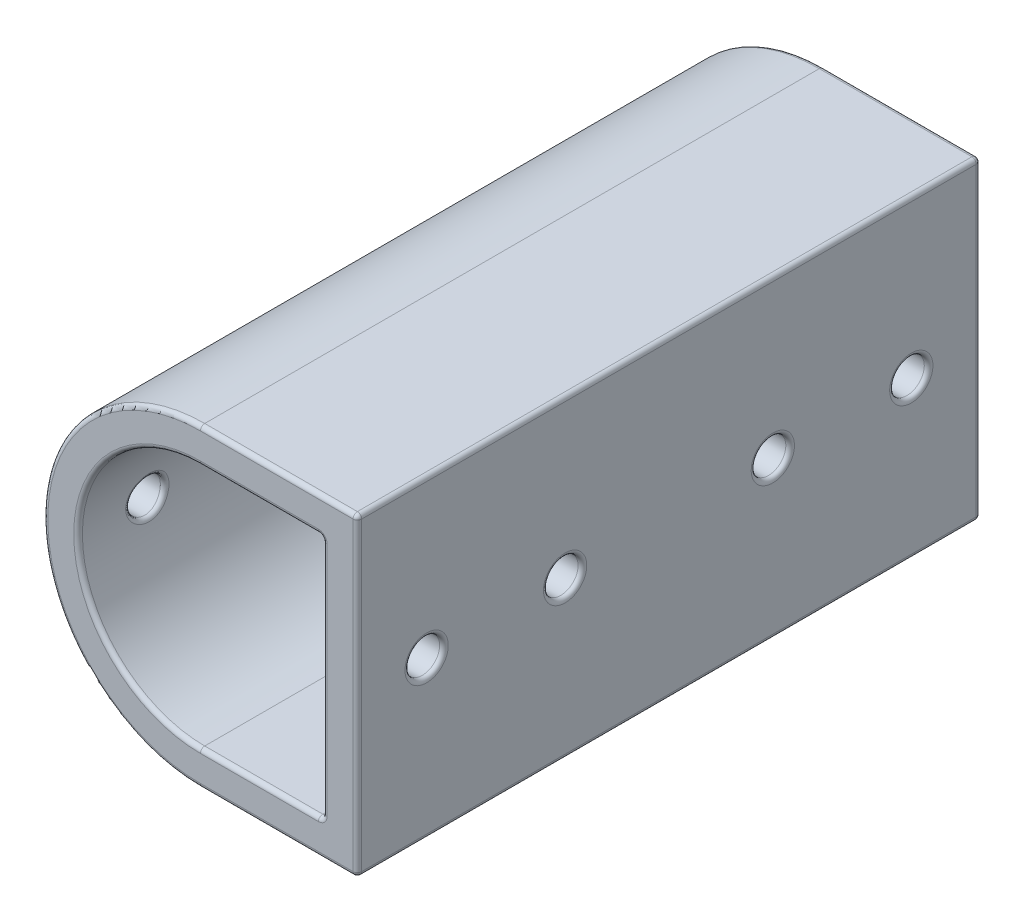
from build123d import *

# Parameters (mm, degrees)
BOSS_EXTRUDE2_DEPTH     = 57.15
CUT_EXTRUDE1_DEPTH      = 57.15
CUT_EXTRUDE1_DEPTH_BACK = 57.15
SKETCH3_R               = 1.5875
CUT_EXTRUDE2_DEPTH      = 38.1
FILLET2_R               = 0.396875


with BuildPart() as part:
    # Sketch2 → Boss-Extrude2 (new body)
    with BuildSketch(Plane.XY):
        with BuildLine():
            Line((0, 13.979196024), (14.39545, 13.979196024))
            Line((14.39545, 13.979196024), (14.39545, -14.811703976))
            Line((14.39545, -14.811703976), (0, -14.811703976))
            ThreePointArc((0, -14.811703976), (-14.39545, -0.416253976), (0, 13.979196024))
        make_face()
    extrude(amount=BOSS_EXTRUDE2_DEPTH)

    # Sketch2_10 → Cut-Extrude1 (cut, two sides: drawn at the far end of the back side and taken through both)
    with BuildSketch(Plane.XY.offset(-CUT_EXTRUDE1_DEPTH_BACK)):
        with BuildLine():
            Line((11.22045, -11.636703976), (0, -11.636703976))
            ThreePointArc((0, -11.636703976), (-11.22045, -0.416253976), (0, 10.804196024))
            Line((0, 10.804196024), (11.22045, 10.804196024))
            Line((11.22045, 10.804196024), (11.22045, -11.636703976))
        make_face()
    extrude(amount=CUT_EXTRUDE1_DEPTH + CUT_EXTRUDE1_DEPTH_BACK, mode=Mode.SUBTRACT)

    # Sketch3 → Cut-Extrude2 (cut)
    with BuildSketch(Plane(origin=(14.39545, 0, 0), x_dir=(0, 0, -1), z_dir=(1, 0, 0))):
        with Locations((-50.8, -0.416253976)):
            Circle(SKETCH3_R)
        with Locations((-38.1, -0.416253976)):
            Circle(SKETCH3_R)
        with Locations((-19.05, -0.416253976)):
            Circle(SKETCH3_R)
        with Locations((-6.35, -0.416253976)):
            Circle(SKETCH3_R)
    extrude(amount=-CUT_EXTRUDE2_DEPTH, mode=Mode.SUBTRACT)

    # Fillet2
    fillet2_edges = [part.edges().sort_by_distance(p)[0] for p in [
        (7.197725, 13.979196024, 57.15),
        (7.197725, -14.811703976, 57.15),
        (7.197725, 13.979196024, 0),
        (7.197725, -14.811703976, 0),
        (5.610225, -11.636703976, 0),
        (5.610225, -11.636703976, 57.15),
        (11.22045, -0.416253976, 57.15),
        (11.22045, -11.636703976, 28.575),
        (11.22045, -0.416253976, 0),
        (11.22045, -0.416253976, 7.9375),
        (11.22045, -0.416253976, 20.6375),
        (11.22045, -0.416253976, 39.6875),
        (11.22045, -0.416253976, 52.3875),
        (14.39545, -14.811703976, 28.575),
        (14.39545, -0.416253976, 57.15),
        (14.39545, 13.979196024, 28.575),
        (14.39545, -0.416253976, 0),
        (14.39545, -0.416253976, 7.9375),
        (14.39545, -0.416253976, 20.6375),
        (14.39545, -0.416253976, 39.6875),
        (14.39545, -0.416253976, 52.3875),
        (5.610225, 10.804196024, 57.15),
        (11.22045, 10.804196024, 28.575),
        (5.610225, 10.804196024, 0),
        (-11.22045, -0.416253976, 0),
        (-11.22045, -0.416253976, 57.15),
        (-11.22045, -0.416253972, 7.937500006),
        (-11.22045, -0.416253972, 20.637500006),
        (-11.22045, -0.416253972, 39.687500006),
        (-11.22045, -0.416253972, 52.387500006),
        (-14.39545, -0.416253976, 57.15),
        (-14.39545, -0.416253976, 0),
        (-14.395450034, -0.416253971, 7.937500008),
        (-14.395450034, -0.416253971, 20.637500008),
        (-14.395450034, -0.416253971, 39.687500008),
        (-14.395450034, -0.416253971, 52.387500008),
    ]]
    fillet(fillet2_edges, radius=FILLET2_R)


solid = part.part
